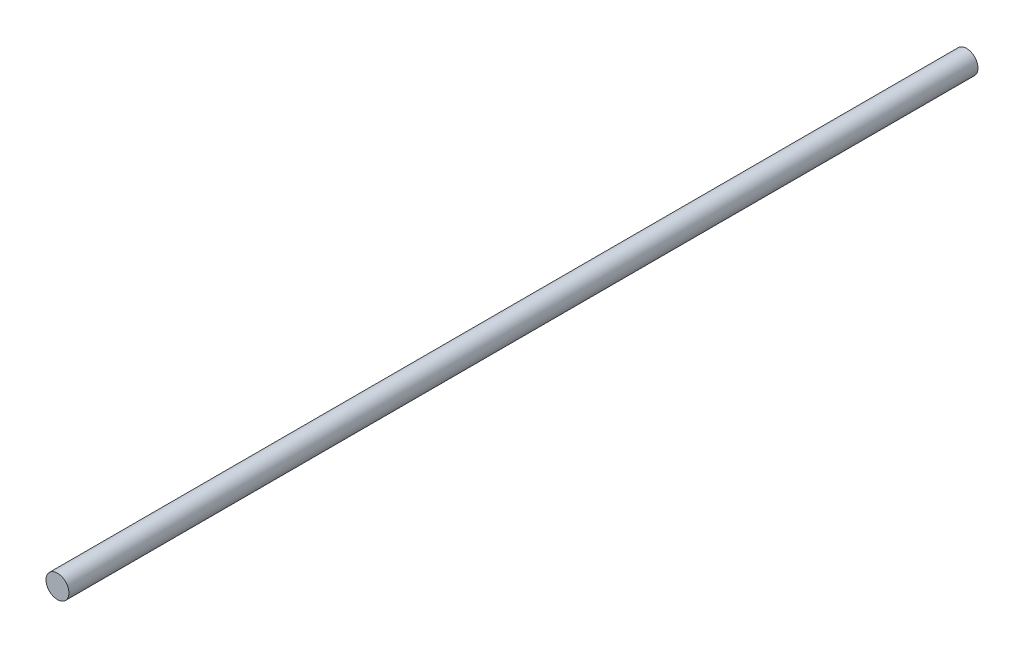
from build123d import *

# Parameters (mm, degrees)
ESBO_O1_R                = 4
RESSALTO_EXTRUS_O1_DEPTH = 158.5


with BuildPart() as part:
    # Esboço1 → Ressalto-extrusão1 (new, symmetric)
    with BuildSketch(Plane.XY):
        Circle(ESBO_O1_R)
    extrude(amount=RESSALTO_EXTRUS_O1_DEPTH, both=True)


solid = part.part
